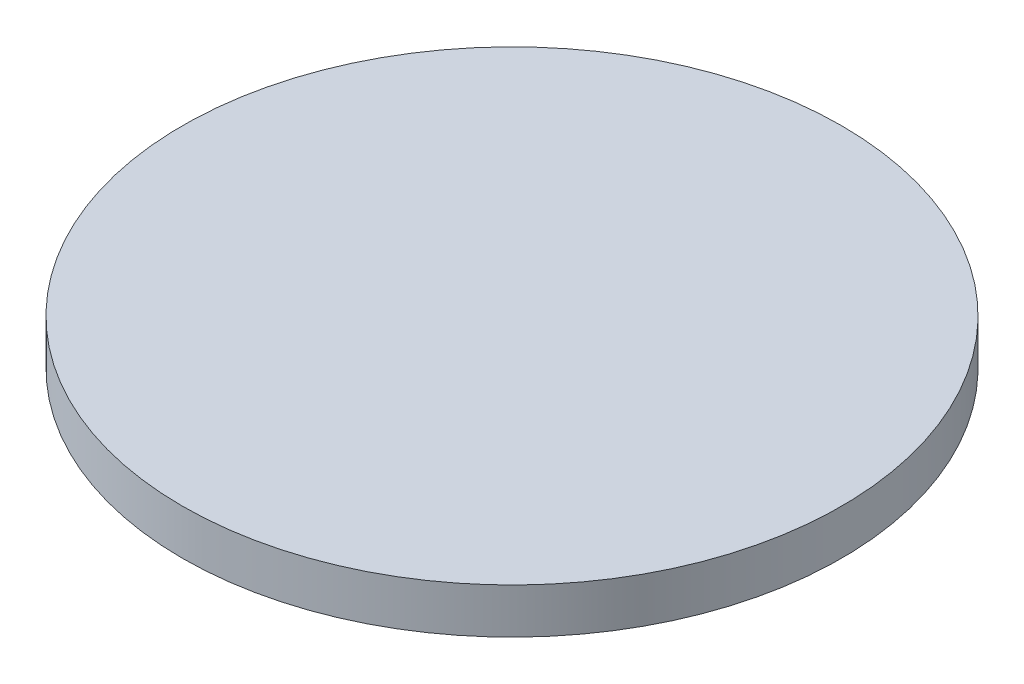
from build123d import *

# Parameters (mm, degrees)
SKETCH1_R           = 72.95
BOSS_EXTRUDE1_DEPTH = 10


with BuildPart() as part:
    # Sketch1 → Boss-Extrude1 (new body)
    with BuildSketch(Plane(origin=(0, 0, 0), x_dir=(1, 0, 0), z_dir=(0, 1, 0))):
        Circle(SKETCH1_R)
    extrude(amount=BOSS_EXTRUDE1_DEPTH)


solid = part.part
